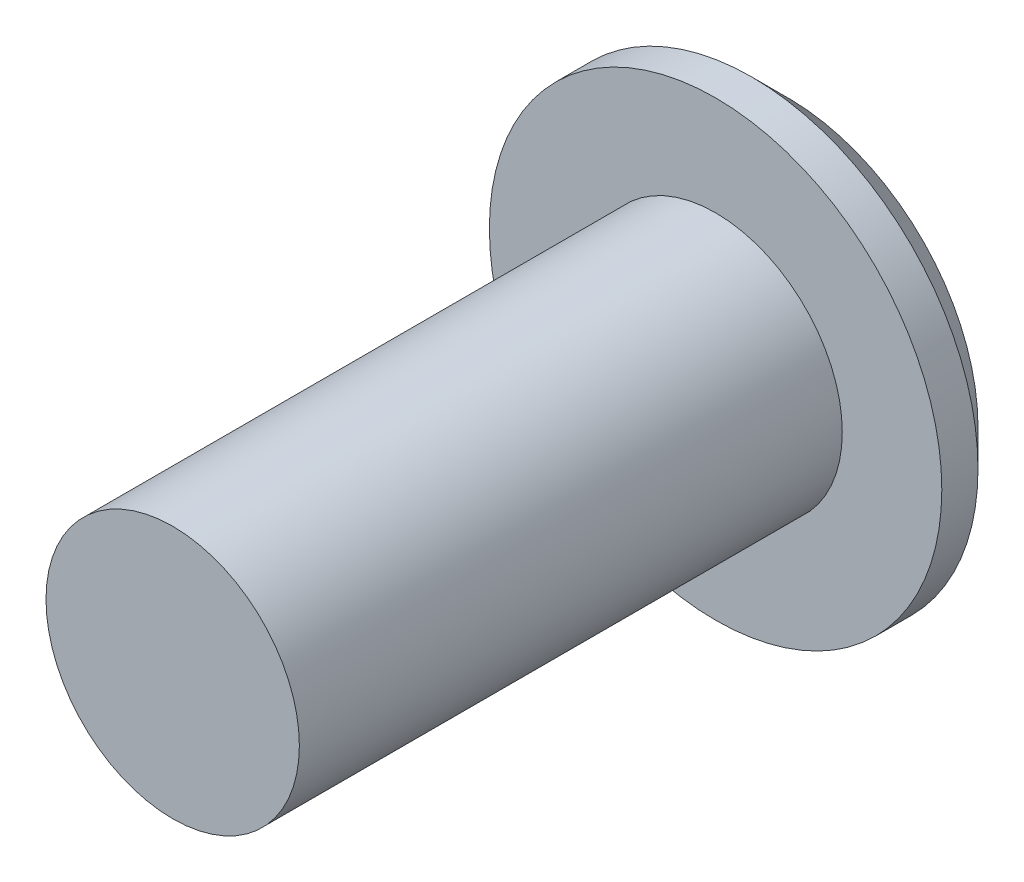
from build123d import *

# Parameters (mm, degrees)
SKETCH1_R           = 12.5
BOSS_EXTRUDE1_DEPTH = 4
SKETCH2_R           = 7
BOSS_EXTRUDE2_DEPTH = 30
CHAMFER1_SIZE       = 2


with BuildPart() as part:
    # Sketch1 → Boss-Extrude1 (new body)
    with BuildSketch(Plane.XY):
        Circle(SKETCH1_R)
    extrude(amount=BOSS_EXTRUDE1_DEPTH)

    # Sketch2 → Boss-Extrude2 (add)
    with BuildSketch(Plane.XY.offset(4)):
        Circle(SKETCH2_R)
    extrude(amount=BOSS_EXTRUDE2_DEPTH)

    # Chamfer1
    chamfer1_edges = [part.edges().sort_by_distance(p)[0] for p in [
        (-12.5, 0, 0),
    ]]
    chamfer(chamfer1_edges, length=CHAMFER1_SIZE)


solid = part.part
